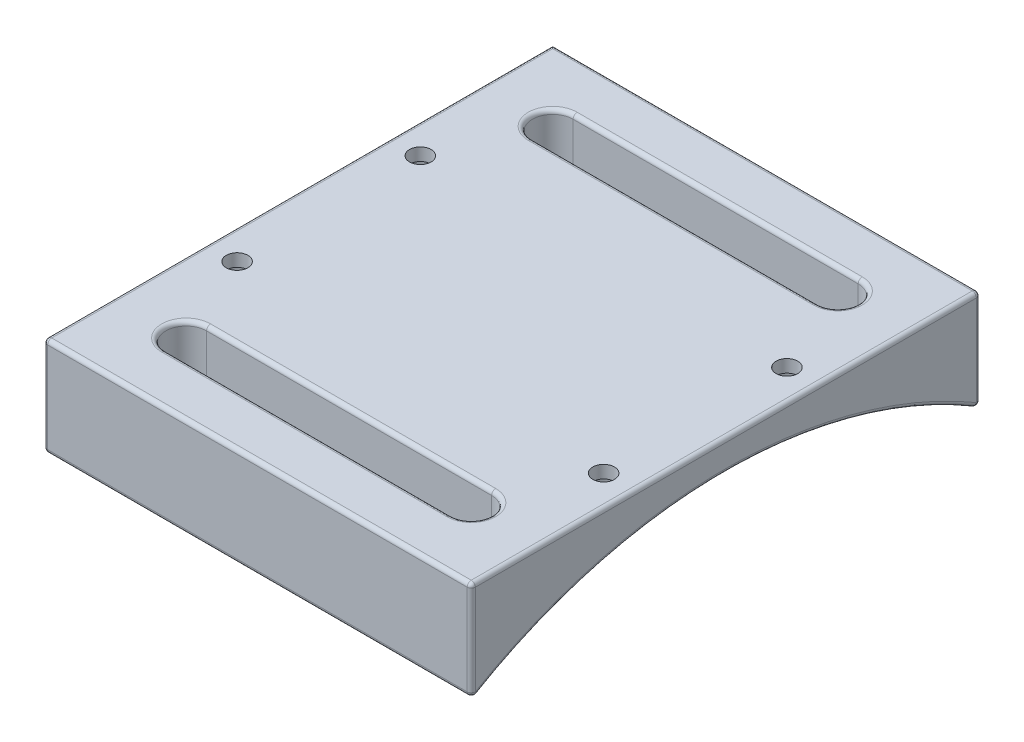
from build123d import *

# Parameters (mm, degrees)
SKETCH1_W                       = 53.34
SKETCH1_H                       = 63.5
BOSS_EXTRUDE1_DEPTH             = 12.7
CUT_EXTRUDE2_DEPTH              = 67.818
CUT_EXTRUDE3_DEPTH              = 54.34
CBORE_FOR_M2_5_SHCS3_AT_2_COUNT = 2
CBORE_FOR_M2_5_SHCS3_AT_2_PITCH = 22.86
CBORE_FOR_M2_5_SHCS3_AT_3_COUNT = 2
CBORE_FOR_M2_5_SHCS3_AT_3_PITCH = 51.116513966
CBORE_FOR_M2_5_SHCS3_AT_4_COUNT = 2
CBORE_FOR_M2_5_SHCS3_AT_4_PITCH = 45.72
SKETCH21_R                      = 3.25
CUT_EXTRUDE4_DEPTH              = 8.6200001
FILLET1_R                       = 0.508


with BuildPart() as part:
    # Sketch1 → Boss-Extrude1 (new body)
    with BuildSketch(Plane(origin=(0, 0, 0), x_dir=(1, 0, 0), z_dir=(0, 1, 0))):
        with Locations((26.67, 31.75)):
            Rectangle(SKETCH1_W, SKETCH1_H)
    extrude(amount=BOSS_EXTRUDE1_DEPTH)

    # Sketch9 → Cut-Extrude2 (cut)
    with BuildSketch(Plane(origin=(0, 12.7, 0), x_dir=(1, 0, 0), z_dir=(0, 1, 0))):
        with BuildLine():
            Line((8.89, 11.43), (44.45, 11.43))
            ThreePointArc((44.45, 11.43), (46.99, 8.89), (44.45, 6.35))
            Line((44.45, 6.35), (8.89, 6.35))
            ThreePointArc((8.89, 6.35), (6.35, 8.89), (8.89, 11.43))
        make_face()
        with BuildLine():
            Line((8.89, 57.15), (44.45, 57.15))
            ThreePointArc((44.45, 57.15), (46.99, 54.61), (44.45, 52.07))
            Line((44.45, 52.07), (8.89, 52.07))
            ThreePointArc((8.89, 52.07), (6.35, 54.61), (8.89, 57.15))
        make_face()
    extrude(amount=-CUT_EXTRUDE2_DEPTH, mode=Mode.SUBTRACT)

    # Sketch11 → Cut-Extrude3 (cut, through all)
    with BuildSketch(Plane(origin=(53.34, 0, 0), x_dir=(0, 0, -1), z_dir=(1, 0, 0))):
        with BuildLine():
            Line((0, 0), (63.5, 0))
            ThreePointArc((63.5, 0), (31.75, 8.89), (0, 0))
        make_face()
    extrude(amount=-CUT_EXTRUDE3_DEPTH, mode=Mode.SUBTRACT)

    # Sketch20 → CBORE for M2.5 SHCS3 (revolve, cut)
    with BuildSketch(Plane(origin=(49.53, 7.62, -20.32), x_dir=(0, 0, -1), z_dir=(1, 0, 0))):
        Polygon((0, 0), (0, 5.08), (1.35, 5.08), (1.35, 3.5), (3.25, 3.5), (3.25, 0), align=None)
    cbore_for_m2_5_shcs3 = revolve(axis=Axis((49.53, 1.27, -20.32), (0, 1, 0)), mode=Mode.SUBTRACT)

    # CBORE for M2.5 SHCS3 at 2: CBORE for M2.5 SHCS3 ×2
    with Locations(*[(0, 0, -i * CBORE_FOR_M2_5_SHCS3_AT_2_PITCH) for i in range(1, CBORE_FOR_M2_5_SHCS3_AT_2_COUNT)]):
        add(cbore_for_m2_5_shcs3, mode=Mode.SUBTRACT)

    # CBORE for M2.5 SHCS3 at 3: CBORE for M2.5 SHCS3 ×2
    with Locations(*[Vector(-0.894427191, 0, -0.447213595) * (i * CBORE_FOR_M2_5_SHCS3_AT_3_PITCH) for i in range(1, CBORE_FOR_M2_5_SHCS3_AT_3_COUNT)]):
        add(cbore_for_m2_5_shcs3, mode=Mode.SUBTRACT)

    # CBORE for M2.5 SHCS3 at 4: CBORE for M2.5 SHCS3 ×2
    with Locations(*[(-i * CBORE_FOR_M2_5_SHCS3_AT_4_PITCH, 0, 0) for i in range(1, CBORE_FOR_M2_5_SHCS3_AT_4_COUNT)]):
        add(cbore_for_m2_5_shcs3, mode=Mode.SUBTRACT)

    # Sketch21 → Cut-Extrude4 (cut, through all)
    with BuildSketch(Plane(origin=(0, 7.62, 0), x_dir=(1, 0, 0), z_dir=(0, 1, 0))):
        with Locations((49.53, 43.18)):
            Circle(SKETCH21_R)
        with Locations((3.81, 43.18)):
            Circle(SKETCH21_R)
        with Locations((3.81, 20.32)):
            Circle(SKETCH21_R)
        with Locations((49.53, 20.32)):
            Circle(SKETCH21_R)
    extrude(amount=-CUT_EXTRUDE4_DEPTH, mode=Mode.SUBTRACT)

    # Fillet1
    fillet1_edges = [part.edges().sort_by_distance(p)[0] for p in [
        (53.34, 12.7, -31.75),
        (26.67, 12.7, -63.5),
        (6.35, 12.7, -8.89),
        (26.67, 12.7, -6.35),
        (46.99, 12.7, -8.89),
        (26.67, 12.7, -11.43),
        (6.35, 12.7, -54.61),
        (26.67, 12.7, -52.07),
        (46.99, 12.7, -54.61),
        (26.67, 12.7, -57.15),
        (0, 12.7, -31.75),
        (26.67, 0, -63.5),
        (26.67, 3.36434516, -6.35),
        (26.67, 0, 0),
        (0, 8.89, -31.75),
        (6.350048963, 4.449306528, -8.874228393),
        (26.67, 5.414608988, -11.43),
        (46.989951035, 4.449306546, -8.874228392),
        (26.67, 5.414608988, -52.07),
        (6.350048935, 4.449306548, -54.625771612),
        (26.67, 3.36434516, -57.15),
        (46.989951036, 4.449306533, -54.625771607),
        (53.34, 8.89, -31.75),
        (53.34, 6.35, -63.5),
        (53.34, 6.35, 0),
        (0, 6.35, 0),
        (26.67, 12.7, 0),
    ]]
    fillet(fillet1_edges, radius=FILLET1_R)


solid = part.part
